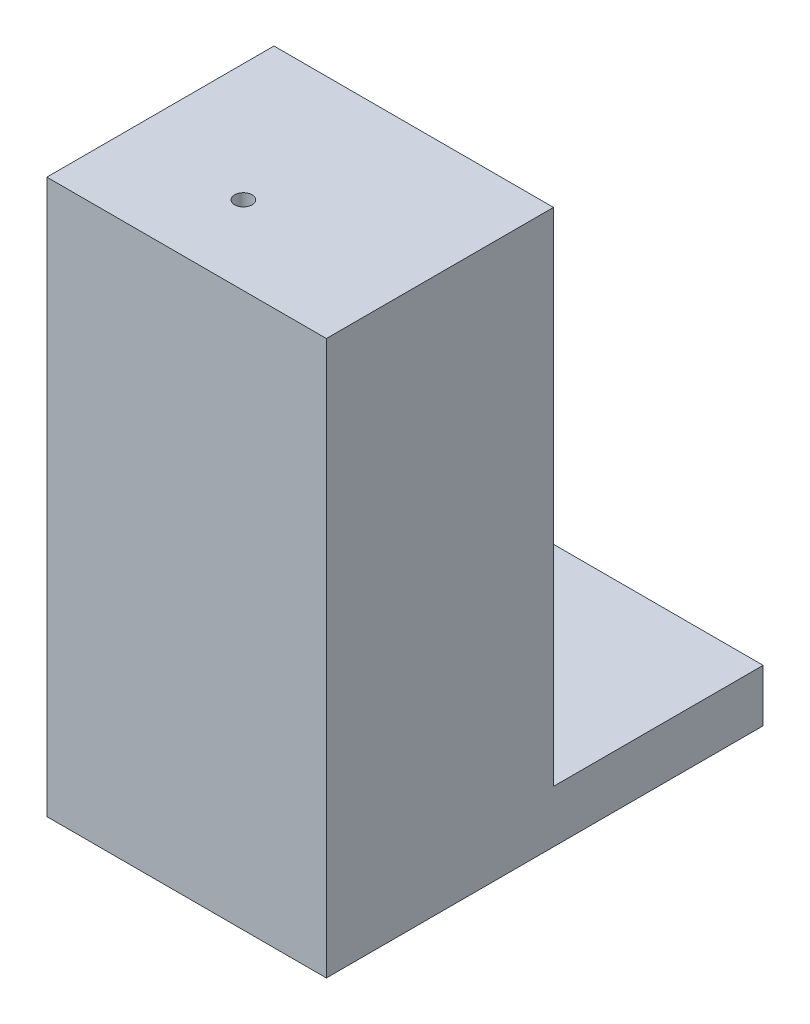
from build123d import *

# Parameters (mm, degrees)
BOSS_EXTRUDE1_DEPTH = 16
SKETCH2_W           = 10
SKETCH2_H           = 18.7
BOSS_EXTRUDE2_DEPTH = 3
CUT_EXTRUDE1_REACH  = 33.7
SKETCH3_R           = 0.5


with BuildPart() as part:
    # Sketch1 → Boss-Extrude1 (new body)
    with BuildSketch(Plane(origin=(0, 0, 0), x_dir=(0, 0, -1), z_dir=(1, 0, 0))):
        Polygon((25, 0), (0, 0), (0, 31.7), (5.035, 31.7), (13, 31.7), (13, 21.7), (3, 21.7), (3, 16.7), (5.4, 16.7), (5.4, 13), (3, 13), (3, 3), (25, 3), align=None)
    extrude(amount=BOSS_EXTRUDE1_DEPTH)

    # Sketch2 → Boss-Extrude2 (add)
    with BuildSketch(Plane(origin=(16, 0, 0), x_dir=(0, 0, -1), z_dir=(1, 0, 0))):
        with Locations((8, 12.35)):
            Rectangle(SKETCH2_W, SKETCH2_H)
    extrude(amount=-BOSS_EXTRUDE2_DEPTH)

    # Sketch3 → Cut-Extrude1 (cut, up to next)
    with BuildSketch(Plane(origin=(0, 31.7, 0), x_dir=(1, 0, 0), z_dir=(0, 1, 0)), mode=Mode.PRIVATE) as cut_extrude1_sk1:
        with Locations((6.75, 4.5)):
            Circle(SKETCH3_R)
    cut_extrude1_tool1 = extrude(cut_extrude1_sk1.sketch, amount=-CUT_EXTRUDE1_REACH, mode=Mode.PRIVATE) & part.part
    add(cut_extrude1_tool1.solids().sort_by_distance((6.75, 31.7, -4.5))[0], mode=Mode.SUBTRACT)


solid = part.part
